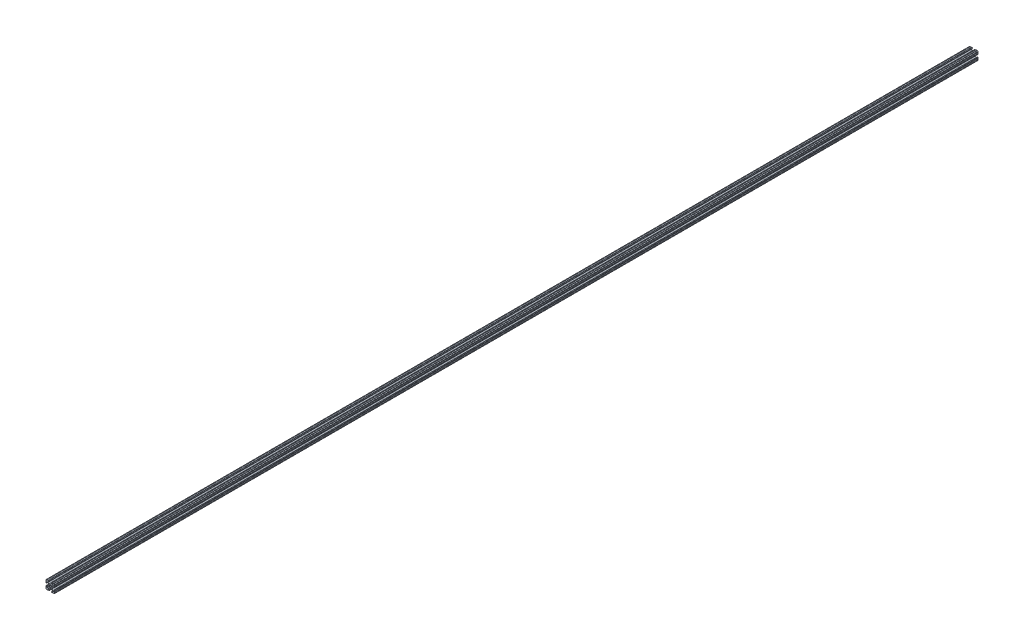
from build123d import *

# Parameters (mm, degrees)
SKETCH3_W                = 25.4
SKETCH3_H                = 25.4
BOSS_EXTRUDE1_DEPTH      = 1371.6
BOSS_EXTRUDE1_DEPTH_BACK = 1371.6
SKETCH4_R                = 2.6035
CUT_EXTRUDE1_DEPTH       = 2744.2
CUT_EXTRUDE2_DEPTH       = 2744.2
FILLET1_R                = 2.54
FILLET2_R                = 1.778


with BuildPart() as part:
    # Sketch3 → Boss-Extrude1 (new body, two sides)
    with BuildSketch(Plane.XY) as boss_extrude1_sk:
        Rectangle(SKETCH3_W, SKETCH3_H)
    extrude(amount=BOSS_EXTRUDE1_DEPTH)
    extrude(boss_extrude1_sk.sketch, amount=-BOSS_EXTRUDE1_DEPTH_BACK)

    # Sketch4 → Cut-Extrude1 (cut, through all)
    with BuildSketch(Plane.XY.offset(1371.6)):
        with BuildLine():
            Line((3.2512, 12.7), (-3.2512, 12.7))
            Line((-3.2512, 12.7), (-3.2512, 10.4902))
            Line((-3.2512, 10.4902), (-6.348478019, 10.4902))
            ThreePointArc((-6.348478019, 10.4902), (-7.335478831, 9.830707141), (-7.103895736, 8.666460301))
            Line((-7.103895736, 8.666460301), (-2.958635435, 4.5212))
            Line((-2.958635435, 4.5212), (2.958635435, 4.5212))
            Line((2.958635435, 4.5212), (7.103895736, 8.666460301))
            ThreePointArc((7.103895736, 8.666460301), (7.335478831, 9.830707141), (6.348478019, 10.4902))
            Line((6.348478019, 10.4902), (3.2512, 10.4902))
            Line((3.2512, 10.4902), (3.2512, 12.7))
        make_face()
        with BuildLine():
            Line((12.7, -3.2512), (12.7, 3.2512))
            Line((12.7, 3.2512), (10.4902, 3.2512))
            Line((10.4902, 3.2512), (10.4902, 6.348478019))
            ThreePointArc((10.4902, 6.348478019), (9.830707141, 7.335478831), (8.666460301, 7.103895736))
            Line((8.666460301, 7.103895736), (4.5212, 2.958635435))
            Line((4.5212, 2.958635435), (4.5212, -2.958635435))
            Line((4.5212, -2.958635435), (8.666460301, -7.103895736))
            ThreePointArc((8.666460301, -7.103895736), (9.830707141, -7.335478831), (10.4902, -6.348478019))
            Line((10.4902, -6.348478019), (10.4902, -3.2512))
            Line((10.4902, -3.2512), (12.7, -3.2512))
        make_face()
        with BuildLine():
            Line((-3.2512, -10.4902), (-3.2512, -12.7))
            Line((-3.2512, -12.7), (3.2512, -12.7))
            Line((3.2512, -12.7), (3.2512, -10.4902))
            Line((3.2512, -10.4902), (6.348478019, -10.4902))
            ThreePointArc((6.348478019, -10.4902), (7.335478831, -9.830707141), (7.103895736, -8.666460301))
            Line((7.103895736, -8.666460301), (2.958635435, -4.5212))
            Line((2.958635435, -4.5212), (-2.958635435, -4.5212))
            Line((-2.958635435, -4.5212), (-7.103895736, -8.666460301))
            ThreePointArc((-7.103895736, -8.666460301), (-7.335478831, -9.830707141), (-6.348478019, -10.4902))
            Line((-6.348478019, -10.4902), (-3.2512, -10.4902))
        make_face()
        with BuildLine():
            Line((-10.4902, 3.2512), (-12.7, 3.2512))
            Line((-12.7, 3.2512), (-12.7, -3.2512))
            Line((-12.7, -3.2512), (-10.4902, -3.2512))
            Line((-10.4902, -3.2512), (-10.4902, -6.348478019))
            ThreePointArc((-10.4902, -6.348478019), (-9.830707141, -7.335478831), (-8.666460301, -7.103895736))
            Line((-8.666460301, -7.103895736), (-4.5212, -2.958635435))
            Line((-4.5212, -2.958635435), (-4.5212, 2.958635435))
            Line((-4.5212, 2.958635435), (-8.666460301, 7.103895736))
            ThreePointArc((-8.666460301, 7.103895736), (-9.830707141, 7.335478831), (-10.4902, 6.348478019))
            Line((-10.4902, 6.348478019), (-10.4902, 3.2512))
        make_face()
        Circle(SKETCH4_R)
    extrude(amount=-CUT_EXTRUDE1_DEPTH, mode=Mode.SUBTRACT)

    # Sketch5 → Cut-Extrude2 (cut, through all)
    with BuildSketch(Plane.XY.offset(1371.6)):
        with BuildLine():
            ThreePointArc((-11.5951, 3.2512), (-12.376382283, 3.574817717), (-12.7, 4.3561))
            Line((-12.7, 4.3561), (-12.7, 3.2512))
            Line((-12.7, 3.2512), (-11.5951, 3.2512))
        make_face()
        with BuildLine():
            ThreePointArc((-10.4902, 4.3561), (-10.813817717, 3.574817717), (-11.5951, 3.2512))
            Line((-11.5951, 3.2512), (-10.4902, 3.2512))
            Line((-10.4902, 3.2512), (-10.4902, 4.3561))
        make_face()
        with BuildLine():
            Line((-12.7, -3.2512), (-12.7, -4.3561))
            ThreePointArc((-12.7, -4.3561), (-12.376382283, -3.574817717), (-11.5951, -3.2512))
            Line((-11.5951, -3.2512), (-12.7, -3.2512))
        make_face()
        with BuildLine():
            Line((-10.4902, -3.2512), (-11.5951, -3.2512))
            ThreePointArc((-11.5951, -3.2512), (-10.813817717, -3.574817717), (-10.4902, -4.3561))
            Line((-10.4902, -4.3561), (-10.4902, -3.2512))
        make_face()
        with BuildLine():
            Line((-3.2512, -11.595100007), (-3.2512, -10.4902))
            Line((-3.2512, -10.4902), (-4.3561, -10.4902))
            ThreePointArc((-4.3561, -10.4902), (-3.574817715, -10.81381772), (-3.2512, -11.595100007))
        make_face()
        with BuildLine():
            Line((-3.2512, -12.7), (-3.2512, -11.595100007))
            ThreePointArc((-3.2512, -11.595100007), (-3.57481772, -12.376382285), (-4.3561, -12.7))
            Line((-4.3561, -12.7), (-3.2512, -12.7))
        make_face()
        with BuildLine():
            Line((3.2512, -10.4902), (3.2512, -11.5951))
            ThreePointArc((3.2512, -11.5951), (3.574817718, -10.813817717), (4.3561, -10.4902))
            Line((4.3561, -10.4902), (3.2512, -10.4902))
        make_face()
        with BuildLine():
            Line((3.2512, -12.7), (4.3561, -12.7))
            ThreePointArc((4.3561, -12.7), (3.574817717, -12.376382282), (3.2512, -11.5951))
            Line((3.2512, -11.5951), (3.2512, -12.7))
        make_face()
        with BuildLine():
            Line((11.5951, -3.2512), (10.4902, -3.2512))
            Line((10.4902, -3.2512), (10.4902, -4.3561))
            ThreePointArc((10.4902, -4.3561), (10.813817717, -3.574817717), (11.5951, -3.2512))
        make_face()
        with BuildLine():
            Line((12.7, -3.2512), (11.5951, -3.2512))
            ThreePointArc((11.5951, -3.2512), (12.376382283, -3.574817717), (12.7, -4.3561))
            Line((12.7, -4.3561), (12.7, -3.2512))
        make_face()
        with BuildLine():
            Line((10.4902, 3.2512), (11.5951, 3.2512))
            ThreePointArc((11.5951, 3.2512), (10.813817717, 3.574817717), (10.4902, 4.3561))
            Line((10.4902, 4.3561), (10.4902, 3.2512))
        make_face()
        with BuildLine():
            Line((12.7, 3.2512), (12.7, 4.3561))
            ThreePointArc((12.7, 4.3561), (12.376382283, 3.574817717), (11.5951, 3.2512))
            Line((11.5951, 3.2512), (12.7, 3.2512))
        make_face()
        with BuildLine():
            Line((3.2512, 12.7), (3.2512, 11.595099996))
            ThreePointArc((3.2512, 11.595099996), (3.574817716, 12.376382281), (4.3561, 12.7))
            Line((4.3561, 12.7), (3.2512, 12.7))
        make_face()
        with BuildLine():
            Line((3.2512, 11.595099996), (3.2512, 10.4902))
            Line((3.2512, 10.4902), (4.3561, 10.4902))
            ThreePointArc((4.3561, 10.4902), (3.574817719, 10.813817716), (3.2512, 11.595099996))
        make_face()
        with BuildLine():
            Line((-3.2512, 12.7), (-4.3561, 12.7))
            ThreePointArc((-4.3561, 12.7), (-3.574817717, 12.376382283), (-3.2512, 11.5951))
            Line((-3.2512, 11.5951), (-3.2512, 12.7))
        make_face()
        with BuildLine():
            Line((-3.2512, 10.4902), (-3.2512, 11.5951))
            ThreePointArc((-3.2512, 11.5951), (-3.574817717, 10.813817717), (-4.3561, 10.4902))
            Line((-4.3561, 10.4902), (-3.2512, 10.4902))
        make_face()
        with BuildLine():
            ThreePointArc((-12.7, 5.23875), (-12.14755, 5.7912), (-12.7, 6.34365))
            Line((-12.7, 6.34365), (-12.7, 5.23875))
        make_face()
        with BuildLine():
            ThreePointArc((-12.7, 9.60755), (-12.14755, 10.16), (-12.7, 10.71245))
            Line((-12.7, 10.71245), (-12.7, 9.60755))
        make_face()
        with BuildLine():
            ThreePointArc((-10.71245, 12.7), (-10.16, 12.14755), (-9.60755, 12.7))
            Line((-9.60755, 12.7), (-10.71245, 12.7))
        make_face()
        with BuildLine():
            ThreePointArc((-6.34365, 12.7), (-5.7912, 12.14755), (-5.23875, 12.7))
            Line((-5.23875, 12.7), (-6.34365, 12.7))
        make_face()
        with BuildLine():
            Line((6.34365, 12.7), (5.23875, 12.7))
            ThreePointArc((5.23875, 12.7), (5.7912, 12.14755), (6.34365, 12.7))
        make_face()
        with BuildLine():
            Line((10.71245, 12.7), (9.60755, 12.7))
            ThreePointArc((9.60755, 12.7), (10.16, 12.14755), (10.71245, 12.7))
        make_face()
        with BuildLine():
            Line((12.7, 10.71245), (12.7, 9.60755))
            ThreePointArc((12.7, 9.60755), (12.14755, 10.16), (12.7, 10.71245))
        make_face()
        with BuildLine():
            Line((12.7, 6.34365), (12.7, 5.23875))
            ThreePointArc((12.7, 5.23875), (12.14755, 5.7912), (12.7, 6.34365))
        make_face()
        with BuildLine():
            Line((-12.7, -6.34365), (-12.7, -5.23875))
            ThreePointArc((-12.7, -5.23875), (-12.14755, -5.7912), (-12.7, -6.34365))
        make_face()
        with BuildLine():
            Line((-12.7, -10.71245), (-12.7, -9.60755))
            ThreePointArc((-12.7, -9.60755), (-12.14755, -10.16), (-12.7, -10.71245))
        make_face()
        with BuildLine():
            Line((-10.71245, -12.7), (-9.60755, -12.7))
            ThreePointArc((-9.60755, -12.7), (-10.16, -12.14755), (-10.71245, -12.7))
        make_face()
        with BuildLine():
            Line((-6.34365, -12.7), (-5.23875, -12.7))
            ThreePointArc((-5.23875, -12.7), (-5.7912, -12.14755), (-6.34365, -12.7))
        make_face()
        with BuildLine():
            Line((12.7, -10.71245), (12.7, -9.60755))
            ThreePointArc((12.7, -9.60755), (12.14755, -10.16), (12.7, -10.71245))
        make_face()
        with BuildLine():
            Line((12.7, -6.34365), (12.7, -5.23875))
            ThreePointArc((12.7, -5.23875), (12.14755, -5.7912), (12.7, -6.34365))
        make_face()
        with BuildLine():
            Line((10.71245, -12.7), (9.60755, -12.7))
            ThreePointArc((9.60755, -12.7), (10.16, -12.14755), (10.71245, -12.7))
        make_face()
        with BuildLine():
            Line((6.34365, -12.7), (5.23875, -12.7))
            ThreePointArc((5.23875, -12.7), (5.7912, -12.14755), (6.34365, -12.7))
        make_face()
    extrude(amount=-CUT_EXTRUDE2_DEPTH, mode=Mode.SUBTRACT)

    # Fillet1
    fillet1_edges = [part.edges().sort_by_distance(p)[0] for p in [
        (2.958635435, 4.5212, 0),
        (-2.958635435, 4.5212, 0),
        (-2.958635435, -4.5212, 0),
        (2.958635435, -4.5212, 0),
        (4.5212, -2.958635435, 0),
        (4.5212, 2.958635435, 0),
        (-4.5212, 2.958635435, 0),
        (-4.5212, -2.958635435, 0),
    ]]
    fillet(fillet1_edges, radius=FILLET1_R)

    # Fillet2
    fillet2_edges = [part.edges().sort_by_distance(p)[0] for p in [
        (-12.7, 12.7, 0),
        (12.7, 12.7, 0),
        (12.7, -12.7, 0),
        (-12.7, -12.7, 0),
    ]]
    fillet(fillet2_edges, radius=FILLET2_R)


solid = part.part
